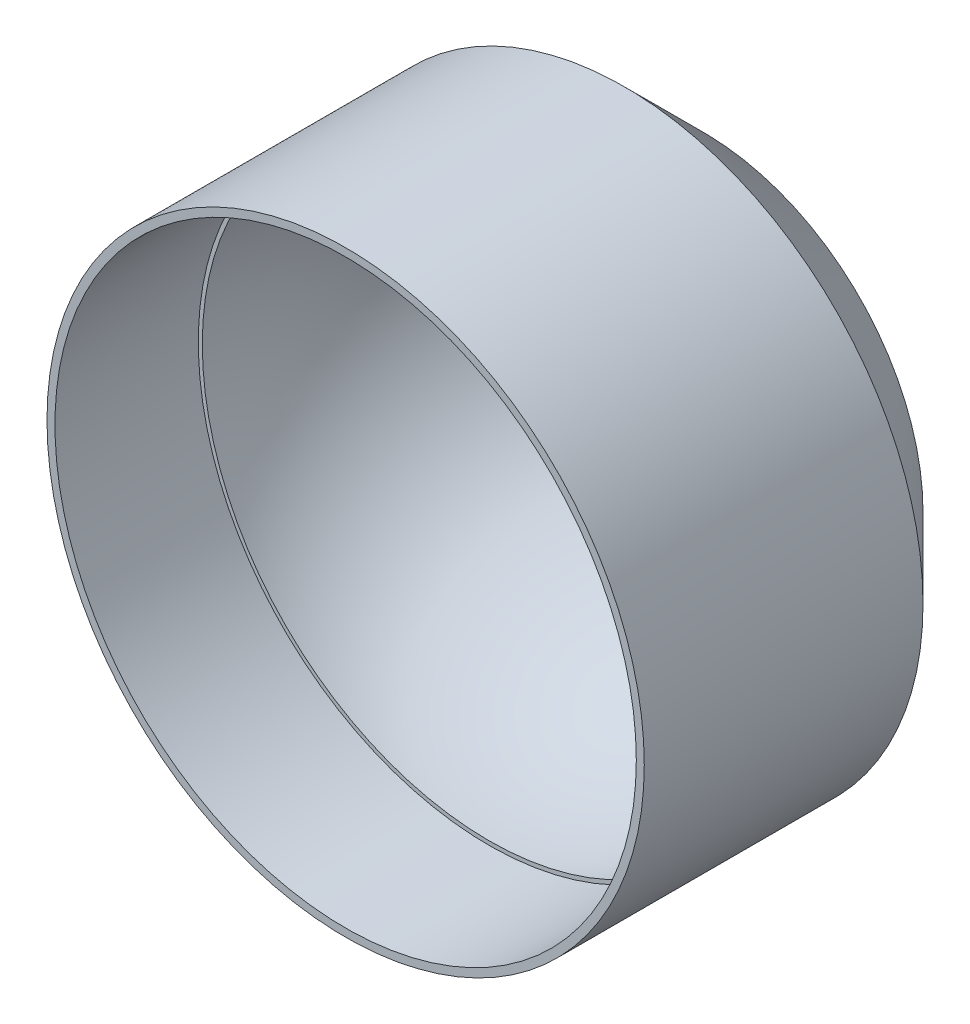
from build123d import *

# Parameters (mm, degrees)
SKETCH1_R           = 37.5
BOSS_EXTRUDE1_DEPTH = 45
SKETCH5_R           = 36.5
CUT_EXTRUDE2_DEPTH  = 18
CUT_REVOLVE3_ANGLE  = 180
CHAMFER1_SIZE       = 10


with BuildPart() as part:
    # Sketch1 → Boss-Extrude1 (new body)
    with BuildSketch(Plane.XY):
        Circle(SKETCH1_R)
    extrude(amount=BOSS_EXTRUDE1_DEPTH)

    # Sketch5 → Cut-Extrude2 (cut)
    with BuildSketch(Plane.XY.offset(45)):
        Circle(SKETCH5_R)
    extrude(amount=-CUT_EXTRUDE2_DEPTH, mode=Mode.SUBTRACT)

    # Sketch7 → Cut-Revolve3 (revolve, cut)
    with BuildSketch(Plane.XY.offset(27)):
        with BuildLine():
            Line((-36, 0), (36, 0))
            ThreePointArc((36, 0), (0, 36), (-36, 0))
        make_face()
    revolve(axis=Axis((-36, 0, 27), (-1, 0, 0)), revolution_arc=CUT_REVOLVE3_ANGLE, mode=Mode.SUBTRACT)

    # Chamfer1
    chamfer1_edges = [part.edges().sort_by_distance(p)[0] for p in [
        (-37.5, 0, 0),
    ]]
    chamfer(chamfer1_edges, length=CHAMFER1_SIZE)


solid = part.part
